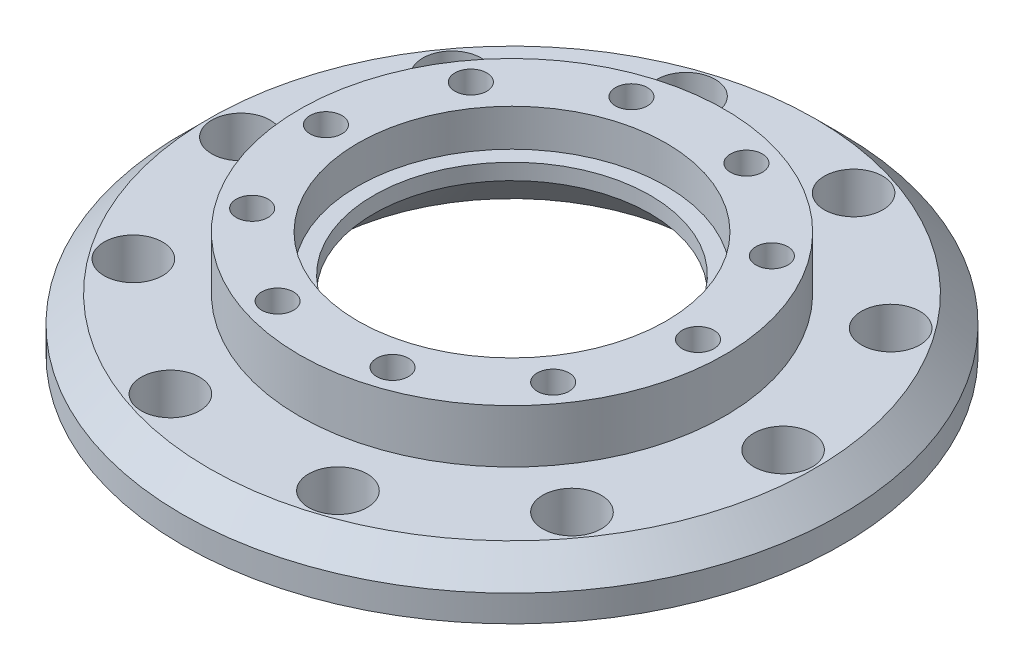
from build123d import *

# Parameters (mm, degrees)
SKETCH1_R           = 62
SKETCH1_R_2         = 5.5
SKETCH1_R_3         = 29
BOSS_EXTRUDE1_DEPTH = 10
SKETCH2_R           = 40
SKETCH2_R_2         = 29
SKETCH2_R_3         = 3
BOSS_EXTRUDE2_DEPTH = 20
BOSS_EXTRUDE3_START = -5
SKETCH3_R           = 3
BOSS_EXTRUDE3_DEPTH = 5
CHAMFER2_SIZE       = 5
CHAMFER3_SIZE       = 1
SKETCH6_R           = 29
SKETCH6_R_2         = 26
BOSS_EXTRUDE4_DEPTH = 13
CHAMFER4_SIZE       = 10


with BuildPart() as part:
    # Sketch1 → Boss-Extrude1 (new body)
    with BuildSketch(Plane(origin=(0, 0, 0), x_dir=(1, 0, 0), z_dir=(0, 1, 0))):
        Circle(SKETCH1_R)
        with Locations((51, 0)):
            Circle(SKETCH1_R_2, mode=Mode.SUBTRACT)
        with Locations((41.259866713, -29.977047867)):
            Circle(SKETCH1_R_2, mode=Mode.SUBTRACT)
        with Locations((15.759866713, -48.503882331)):
            Circle(SKETCH1_R_2, mode=Mode.SUBTRACT)
        with Locations((-15.759866713, -48.503882331)):
            Circle(SKETCH1_R_2, mode=Mode.SUBTRACT)
        with Locations((-41.259866713, -29.977047867)):
            Circle(SKETCH1_R_2, mode=Mode.SUBTRACT)
        with Locations((-51, 0)):
            Circle(SKETCH1_R_2, mode=Mode.SUBTRACT)
        with Locations((-41.259866713, 29.977047867)):
            Circle(SKETCH1_R_2, mode=Mode.SUBTRACT)
        with Locations((-15.759866713, 48.503882331)):
            Circle(SKETCH1_R_2, mode=Mode.SUBTRACT)
        with Locations((15.759866713, 48.503882331)):
            Circle(SKETCH1_R_2, mode=Mode.SUBTRACT)
        with Locations((41.259866713, 29.977047867)):
            Circle(SKETCH1_R_2, mode=Mode.SUBTRACT)
        Circle(SKETCH1_R_3, mode=Mode.SUBTRACT)
    extrude(amount=BOSS_EXTRUDE1_DEPTH)

    # Sketch2 → Boss-Extrude2 (add)
    with BuildSketch(Plane(origin=(0, 0, 0), x_dir=(1, 0, 0), z_dir=(0, 1, 0))):
        Circle(SKETCH2_R)
        Circle(SKETCH2_R_2, mode=Mode.SUBTRACT)
        with Locations((35, 0)):
            Circle(SKETCH2_R_3, mode=Mode.SUBTRACT)
        with Locations((28.315594803, -20.57248383)):
            Circle(SKETCH2_R_3, mode=Mode.SUBTRACT)
        with Locations((10.815594803, -33.28697807)):
            Circle(SKETCH2_R_3, mode=Mode.SUBTRACT)
        with Locations((-10.815594803, -33.28697807)):
            Circle(SKETCH2_R_3, mode=Mode.SUBTRACT)
        with Locations((-28.315594803, -20.57248383)):
            Circle(SKETCH2_R_3, mode=Mode.SUBTRACT)
        with Locations((-35, 0)):
            Circle(SKETCH2_R_3, mode=Mode.SUBTRACT)
        with Locations((-28.315594803, 20.57248383)):
            Circle(SKETCH2_R_3, mode=Mode.SUBTRACT)
        with Locations((-10.815594803, 33.28697807)):
            Circle(SKETCH2_R_3, mode=Mode.SUBTRACT)
        with Locations((10.815594803, 33.28697807)):
            Circle(SKETCH2_R_3, mode=Mode.SUBTRACT)
        with Locations((28.315594803, 20.57248383)):
            Circle(SKETCH2_R_3, mode=Mode.SUBTRACT)
    extrude(amount=BOSS_EXTRUDE2_DEPTH)

    # Sketch3 → Boss-Extrude3 (add)
    with BuildSketch(Plane(origin=(0, 20, 0), x_dir=(1, 0, 0), z_dir=(0, 1, 0)).offset(BOSS_EXTRUDE3_START)):
        with Locations((-28.315594803, -20.57248383)):
            Circle(SKETCH3_R)
        with Locations((-35, 0)):
            Circle(SKETCH3_R)
        with Locations((-28.315594803, 20.57248383)):
            Circle(SKETCH3_R)
        with Locations((-10.815594803, 33.28697807)):
            Circle(SKETCH3_R)
        with Locations((10.815594803, 33.28697807)):
            Circle(SKETCH3_R)
        with Locations((28.315594803, 20.57248383)):
            Circle(SKETCH3_R)
        with Locations((35, 0)):
            Circle(SKETCH3_R)
        with Locations((28.315594803, -20.57248383)):
            Circle(SKETCH3_R)
        with Locations((10.815594803, -33.28697807)):
            Circle(SKETCH3_R)
        with Locations((-10.815594803, -33.28697807)):
            Circle(SKETCH3_R)
    extrude(amount=-BOSS_EXTRUDE3_DEPTH)

    # Chamfer2
    chamfer2_edges = [part.edges().sort_by_distance(p)[0] for p in [
        (-62, 10, 0),
    ]]
    chamfer(chamfer2_edges, length=CHAMFER2_SIZE)

    # Chamfer3
    chamfer3_edges = [part.edges().sort_by_distance(p)[0] for p in [
        (10.259866713, 0, -48.503882331),
        (-21.259866713, 0, -48.503882331),
        (-46.759866713, 0, -29.977047867),
        (-56.5, 0, 0),
        (-46.759866713, 0, 29.977047867),
        (-21.259866713, 0, 48.503882331),
        (10.259866713, 0, 48.503882331),
        (35.759866713, 0, 29.977047867),
        (45.5, 0, 0),
        (35.759866713, 0, -29.977047867),
    ]]
    chamfer(chamfer3_edges, length=CHAMFER3_SIZE)

    # Sketch6 → Boss-Extrude4 (add)
    with BuildSketch(Plane.XZ):
        Circle(SKETCH6_R)
        Circle(SKETCH6_R_2, mode=Mode.SUBTRACT)
    extrude(amount=-BOSS_EXTRUDE4_DEPTH)

    # Chamfer4
    chamfer4_edges = [part.edges().sort_by_distance(p)[0] for p in [
        (-26, 0, 0),
    ]]
    chamfer(chamfer4_edges, length=CHAMFER4_SIZE)


solid = part.part
